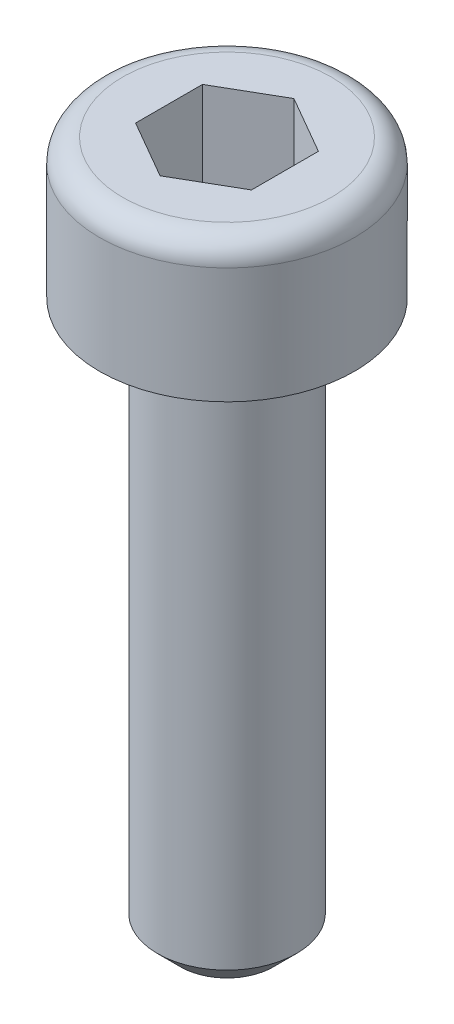
from build123d import *

# Parameters (mm, degrees)
CORTAR_EXTRUIR1_DEPTH = 2
CHAFL_N1_SIZE         = 0.5
REDONDEO1_R           = 0.5


with BuildPart() as part:
    # Croquis1 → Revolución1 (revolve)
    with BuildSketch(Plane.XY):
        Polygon((0, 0), (2.75, 0), (2.75, -3), (1.5, -3), (1.5, -15), (0, -15), align=None)
    revolve(axis=Axis((0, 0, 0), (0, -1, 0)))

    # Croquis2 → Cortar-Extruir1 (cut)
    with BuildSketch(Plane(origin=(0, 0, 0), x_dir=(1, 0, 0), z_dir=(0, 1, 0))):
        Polygon((1.25, 0.721687836), (0, 1.443375673), (-1.25, 0.721687836), (-1.25, -0.721687836), (0, -1.443375673), (1.25, -0.721687836), align=None)
    extrude(amount=-CORTAR_EXTRUIR1_DEPTH, mode=Mode.SUBTRACT)

    # Chaflán1
    chafl_n1_edges = [part.edges().sort_by_distance(p)[0] for p in [
        (-1.5, -15, 0),
    ]]
    chamfer(chafl_n1_edges, length=CHAFL_N1_SIZE)

    # Redondeo1
    redondeo1_edges = [part.edges().sort_by_distance(p)[0] for p in [
        (-2.75, 0, 0),
    ]]
    fillet(redondeo1_edges, radius=REDONDEO1_R)


solid = part.part
